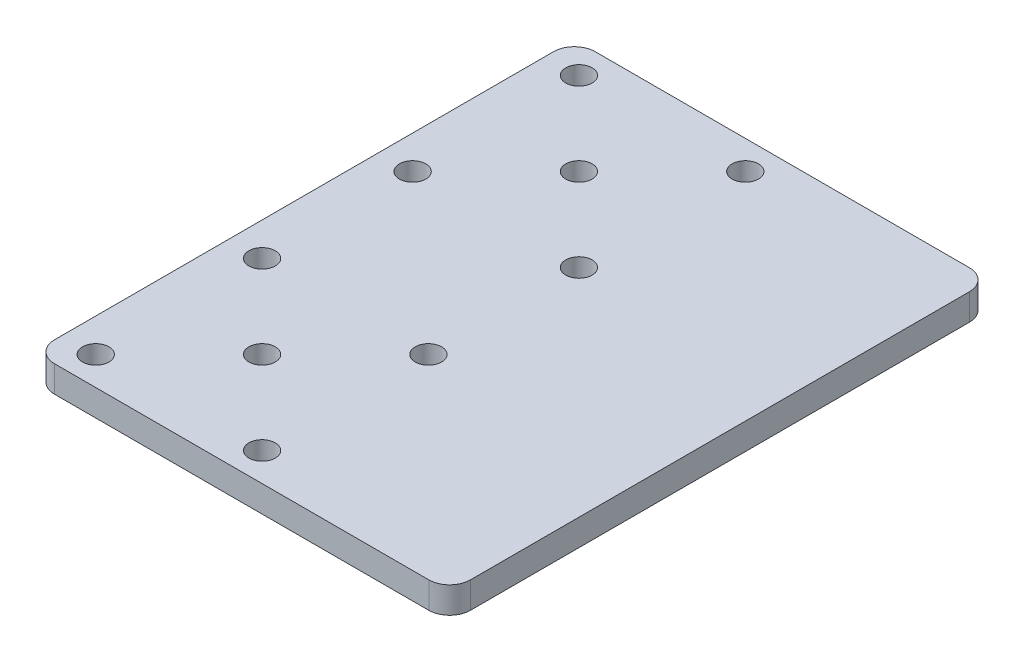
from build123d import *

# Parameters (mm, degrees)
SKETCH1_W                   = 100
SKETCH1_H                   = 130
BOSS_EXTRUDE1_DEPTH         = 6.35
FILLET1_R                   = 5
F_1_4_0_25_DIAMETER_HOLE1_D = 6.35


with BuildPart() as part:
    # Sketch1 → Boss-Extrude1 (new body)
    with BuildSketch(Plane(origin=(0, 0, 0), x_dir=(1, 0, 0), z_dir=(0, 1, 0))):
        Rectangle(SKETCH1_W, SKETCH1_H)
    extrude(amount=BOSS_EXTRUDE1_DEPTH)

    # Fillet1
    fillet1_edges = [part.edges().sort_by_distance(p)[0] for p in [
        (-50, 3.175, 65),
        (-50, 3.175, -65),
        (50, 3.175, -65),
        (50, 3.175, 65),
    ]]
    fillet(fillet1_edges, radius=FILLET1_R)

    # 1/4 (0.25) Diameter Hole1 (through all)
    with Locations(Plane(origin=(0, 6.35, 0), x_dir=(1, 0, 0), z_dir=(0, 1, 0))):
        with Locations((-42, -18.1), (-2, -18.1), (-2, -58.1), (-42, -58.1), (-22, -38.1)):
            f_1_4_0_25_diameter_hole1 = Hole(F_1_4_0_25_DIAMETER_HOLE1_D / 2)

    # Mirror1: 1/4 (0.25) Diameter Hole1 across plane
    add(f_1_4_0_25_diameter_hole1.mirror(Plane.XY), mode=Mode.SUBTRACT)


solid = part.part
